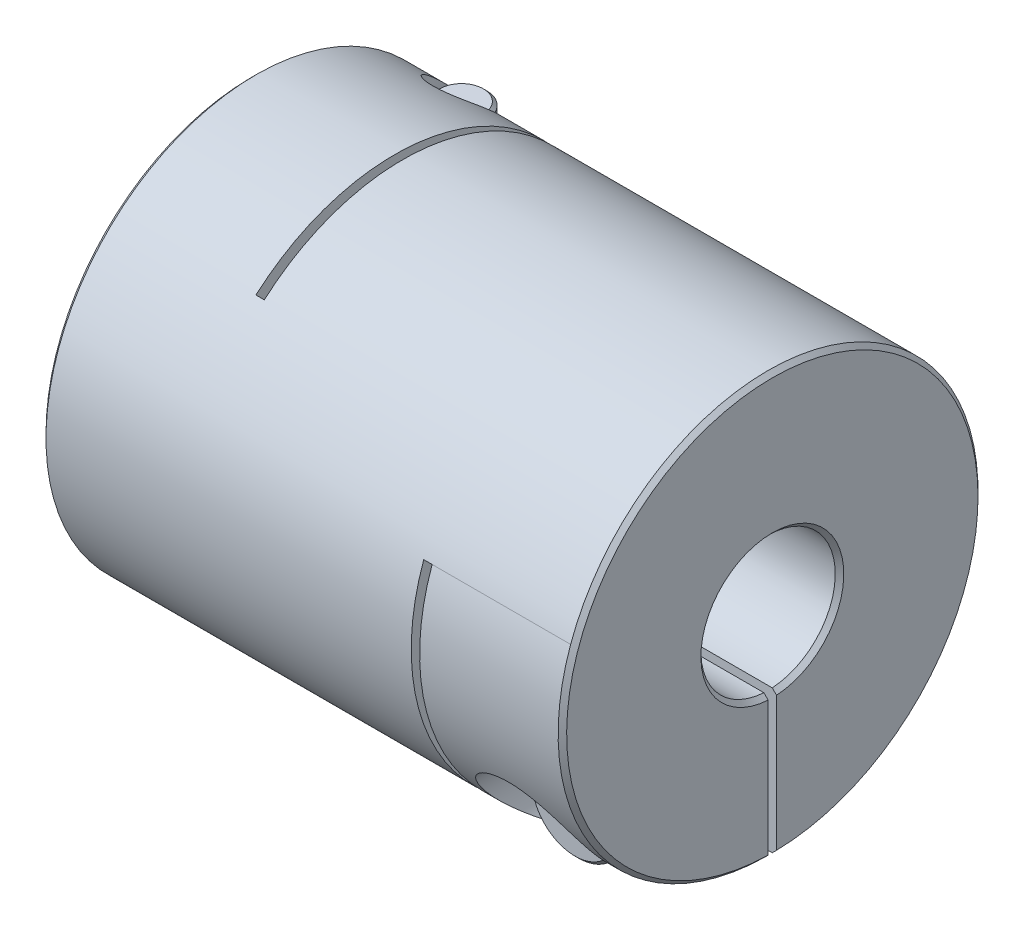
from build123d import *

# Parameters (mm, degrees)
SKETCH1_R                      = 12.5
BOSS_EXTRUDE1_DEPTH            = 15.5
SKETCH2_R                      = 4
CUT_EXTRUDE1_DEPTH             = 32
CHAMFER1_SIZE                  = 0.254
SKETCH4_W                      = 0.5
SKETCH4_H                      = 20.75
CUT_EXTRUDE2_DEPTH             = 26
SKETCH7_W                      = 0.5
SKETCH7_H                      = 16.75
CUT_EXTRUDE3_DEPTH             = 26
SKETCH8_W                      = 8.5
SKETCH8_H                      = 12.5
CUT_EXTRUDE5_DEPTH             = 0.25
SKETCH13_W                     = 8.5
SKETCH13_H                     = 12.5
CUT_EXTRUDE6_DEPTH             = 0.25
CBORE_FOR_M3_SHCS1_D           = 3.4
CBORE_FOR_M3_SHCS1_CBORE_D     = 6.5
CBORE_FOR_M3_SHCS1_CBORE_DEPTH = 8
CBORE_FOR_M3_SHCS2_D           = 3.4
CBORE_FOR_M3_SHCS2_CBORE_D     = 6.5
CBORE_FOR_M3_SHCS2_CBORE_DEPTH = 8
SKETCH16_R                     = 2.75
BOSS_EXTRUDE2_DEPTH            = 3
SKETCH17_R                     = 1.5
BOSS_EXTRUDE3_DEPTH            = 13.5
CHAMFER2_SIZE                  = 0.2
CUT_EXTRUDE7_DEPTH             = 1.5
CIRPATTERN1_COUNT              = 2
CIRPATTERN1_ANGLE              = 90


with BuildPart() as part:
    # Sketch1 → Boss-Extrude1 (new body, symmetric)
    with BuildSketch(Plane(origin=(0, 0, 0), x_dir=(0, 0, -1), z_dir=(1, 0, 0))):
        Circle(SKETCH1_R)
    extrude(amount=BOSS_EXTRUDE1_DEPTH, both=True)

    # Sketch2 → Cut-Extrude1 (cut, through all)
    with BuildSketch(Plane(origin=(15.5, 0, 0), x_dir=(0, 0, -1), z_dir=(1, 0, 0))):
        Circle(SKETCH2_R)
    extrude(amount=-CUT_EXTRUDE1_DEPTH, mode=Mode.SUBTRACT)

    # Chamfer1
    chamfer1_edges = [part.edges().sort_by_distance(p)[0] for p in [
        (-15.5, 0, 12.5),
        (15.5, 0, 12.5),
        (-15.5, 0, 4),
        (15.5, 0, 4),
    ]]
    chamfer(chamfer1_edges, length=CHAMFER1_SIZE)

    # Sketch4 → Cut-Extrude2 (cut, through all)
    with BuildSketch(Plane.XZ.offset(12.5)):
        with Locations((-6.75, -2.125)):
            Rectangle(SKETCH4_W, SKETCH4_H)
    extrude(amount=-CUT_EXTRUDE2_DEPTH, mode=Mode.SUBTRACT)

    # Sketch7 → Cut-Extrude3 (cut, through all)
    with BuildSketch(Plane(origin=(0, 0, -12.5), x_dir=(-1, 0, 0), z_dir=(0, 0, -1))):
        with Locations((-6.75, -4.125)):
            Rectangle(SKETCH7_W, SKETCH7_H)
    extrude(amount=-CUT_EXTRUDE3_DEPTH, mode=Mode.SUBTRACT)

    # Sketch8 → Cut-Extrude5 (cut, symmetric)
    with BuildSketch(Plane(origin=(0, 0, 0), x_dir=(1, 0, 0), z_dir=(0, 1, 0))):
        with Locations((-11.25, 6.25)):
            Rectangle(SKETCH8_W, SKETCH8_H)
    extrude(amount=CUT_EXTRUDE5_DEPTH, both=True, mode=Mode.SUBTRACT)

    # Sketch13 → Cut-Extrude6 (cut, symmetric)
    with BuildSketch(Plane.XY):
        with Locations((11.25, -6.25)):
            Rectangle(SKETCH13_W, SKETCH13_H)
    extrude(amount=CUT_EXTRUDE6_DEPTH, both=True, mode=Mode.SUBTRACT)

    # CBORE for M3 SHCS1 (through all)
    with Locations(Plane.XZ.offset(12.5)):
        with Locations((-11.25, -8.244839803)):
            CounterBoreHole(CBORE_FOR_M3_SHCS1_D / 2, CBORE_FOR_M3_SHCS1_CBORE_D / 2, CBORE_FOR_M3_SHCS1_CBORE_DEPTH)

    # CBORE for M3 SHCS2 (through all)
    with Locations(Plane.XY.offset(12.5)):
        with Locations((11.25, -8.244839803)):
            CounterBoreHole(CBORE_FOR_M3_SHCS2_D / 2, CBORE_FOR_M3_SHCS2_CBORE_D / 2, CBORE_FOR_M3_SHCS2_CBORE_DEPTH)


with BuildPart() as body_2:
    # Sketch16 → Boss-Extrude2 (new body)
    with BuildSketch(Plane.XY.offset(4.5)):
        with Locations((11.25, -8.244839803)):
            Circle(SKETCH16_R)
    extrude(amount=BOSS_EXTRUDE2_DEPTH)

    # Sketch17 → Boss-Extrude3 (add)
    with BuildSketch(Plane(origin=(0, 0, 4.5), x_dir=(-1, 0, 0), z_dir=(0, 0, -1))):
        with Locations(Location((-11.25, -8.244839803, 0), (0, 0, 180))):  # turned: the seam where the file's is
            Circle(SKETCH17_R)
    extrude(amount=BOSS_EXTRUDE3_DEPTH)

    # Chamfer2
    chamfer2_edges = [body_2.edges().sort_by_distance(p)[0] for p in [
        (8.5, -8.244839803, 4.5),
        (8.5, -8.244839803, 7.5),
        (9.75, -8.244839803, -9),
    ]]
    chamfer(chamfer2_edges, length=CHAMFER2_SIZE)

    # Sketch18 → Cut-Extrude7 (cut)
    with BuildSketch(Plane.XY.offset(7.5)):
        Polygon((11.25, -9.688215476), (12.5, -8.966527639), (12.5, -7.523151966), (11.25, -6.80146413), (10, -7.523151966), (10, -8.966527639), align=None)
    extrude(amount=-CUT_EXTRUDE7_DEPTH, mode=Mode.SUBTRACT)


with BuildPart() as body_3:
    # Mirror1: mirrored copy
    add(body_2.part.mirror(Plane(origin=(0, 0, 0), x_dir=(0, 0, 1), z_dir=(1, 0, 0))))


with BuildPart() as cirpattern1_1:
    # CirPattern1: pattern copy
    add(body_3.part.rotate(Axis((0, 0, 0), (1, 0, 0)), 1 * CIRPATTERN1_ANGLE / (CIRPATTERN1_COUNT - 1)))


solid = Compound([part.part, body_2.part, cirpattern1_1.part])
